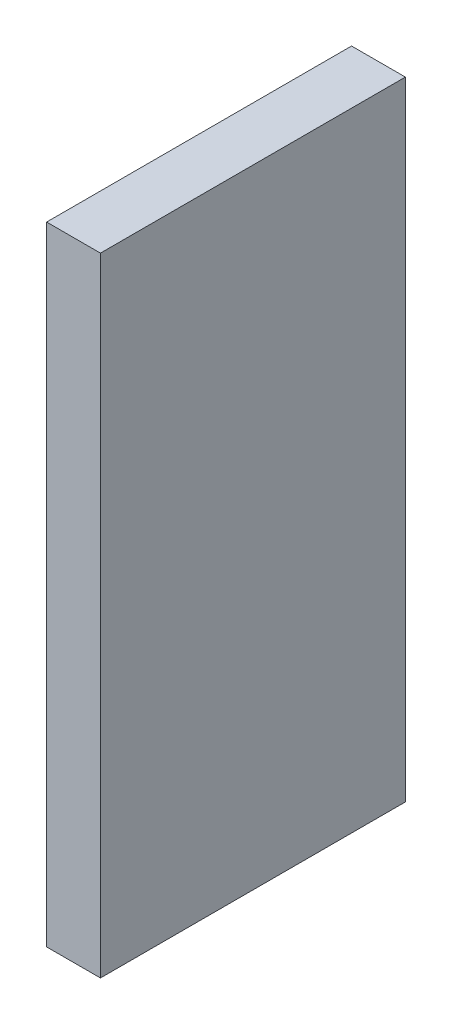
from build123d import *

# Parameters (mm, degrees)
SKETCH4_W           = 3
SKETCH4_H           = 35
BOSS_EXTRUDE1_DEPTH = 17


with BuildPart() as part:
    # Sketch4 → Boss-Extrude1 (new body)
    with BuildSketch(Plane.XY):
        with Locations((6.270283309, 39.811583722)):
            Rectangle(SKETCH4_W, SKETCH4_H)
    extrude(amount=BOSS_EXTRUDE1_DEPTH)


solid = part.part
